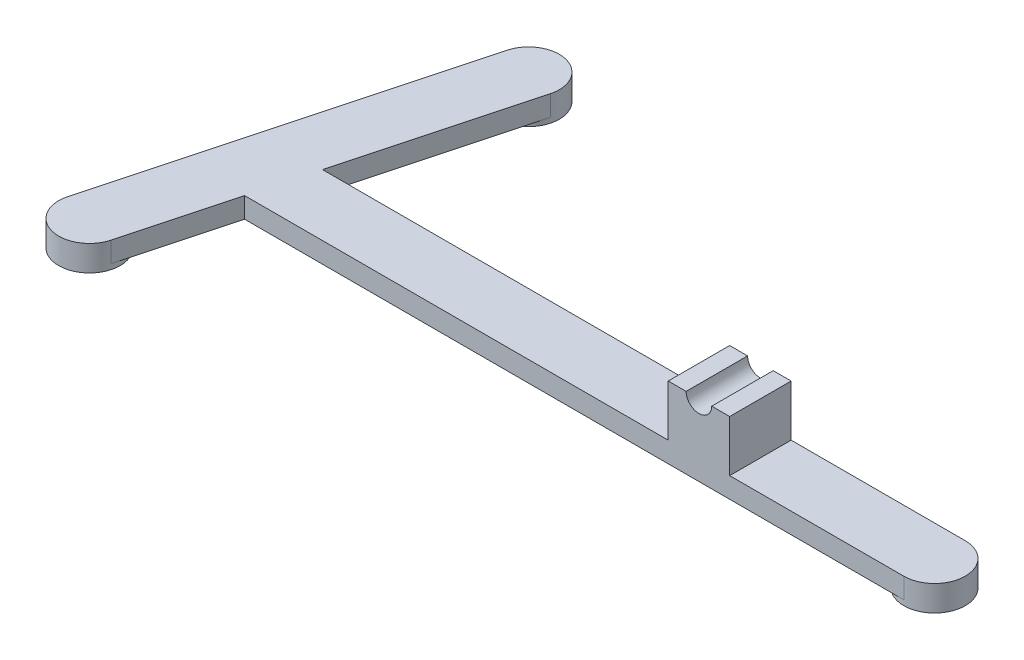
from build123d import *

# Parameters (mm, degrees)
BOSS_EXTRUDE3_DEPTH      = 4
BOSS_EXTRUDE3_2_DEPTH    = 4
BOSS_EXTRUDE4_DEPTH      = 4
BOSS_EXTRUDE4_DEPTH_BACK = 1
SKETCH2_5_R              = 6
SKETCH2_6_W              = 12
SKETCH2_6_H              = 12
BOSS_EXTRUDE5_DEPTH      = 14
SKETCH3_R                = 2.5
CUT_EXTRUDE1_DEPTH       = 14


with BuildPart() as part:
    # Sketch2 → Boss-Extrude3 (new body)
    with BuildSketch(Plane(origin=(0, 0, 0), x_dir=(1, 0, 0), z_dir=(0, 1, 0))):
        with BuildLine():
            ThreePointArc((-6.676022794, -14.008494556), (0.672446434, -9.765853869), (4.915087121, -17.114323097))
            Line((4.915087121, -17.114323097), (10.422223902, 3.438591174))
            Line((10.422223902, 3.438591174), (93.119532163, 3.438591174))
            Line((93.119532163, 3.438591174), (93.119532163, 15.438591174))
            Line((93.119532163, 15.438591174), (13.637614211, 15.438591174))
            Line((13.637614211, 15.438591174), (23.032420278, 50.500484743))
            ThreePointArc((23.032420278, 50.500484743), (15.68395105, 46.257844056), (11.441310363, 53.606313284))
            Line((11.441310363, 53.606313284), (-6.676022794, -14.008494556))
        make_face()
    extrude(amount=BOSS_EXTRUDE3_DEPTH)



with BuildPart() as body_2:
    # Sketch2 → Boss-Extrude3 2 (new body)
    with BuildSketch(Plane(origin=(0, 0, 0), x_dir=(1, 0, 0), z_dir=(0, 1, 0))):
        with BuildLine():
            Line((105.119532163, 15.438591174), (105.119532163, 3.438591174))
            Line((105.119532163, 3.438591174), (139.119532163, 3.438591174))
            ThreePointArc((139.119532163, 3.438591174), (133.119532163, 9.438591174), (139.119532163, 15.438591174))
            Line((139.119532163, 15.438591174), (105.119532163, 15.438591174))
        make_face()
    extrude(amount=BOSS_EXTRUDE3_2_DEPTH)


with BuildPart() as part_1:
    add(part.part)

    add(body_2.part)  # Boss-Extrude4 merges body 2
    # Sketch2_5 → Boss-Extrude4 (add, two sides: drawn at the far end of the back side and taken through both)
    with BuildSketch(Plane(origin=(0, 0, 0), x_dir=(1, 0, 0), z_dir=(0, 1, 0)).offset(-BOSS_EXTRUDE4_DEPTH_BACK)):
        with Locations((-0.880467837, -15.561408826)):
            Circle(SKETCH2_5_R)
        with Locations((17.236865321, 52.053399014)):
            Circle(SKETCH2_5_R)
        with Locations((139.119532163, 9.438591174)):
            Circle(SKETCH2_5_R)
    extrude(amount=BOSS_EXTRUDE4_DEPTH + BOSS_EXTRUDE4_DEPTH_BACK)

    # Sketch2_6 → Boss-Extrude5 (add)
    with BuildSketch(Plane(origin=(0, 0, 0), x_dir=(1, 0, 0), z_dir=(0, 1, 0))):
        with Locations((99.119532163, 9.438591174)):
            Rectangle(SKETCH2_6_W, SKETCH2_6_H)
    extrude(amount=BOSS_EXTRUDE5_DEPTH)

    # Sketch3 → Cut-Extrude1 (cut)
    with BuildSketch(Plane.XY.offset(-3.438591174)):
        with Locations((99.119532163, 14)):
            Circle(SKETCH3_R)
    extrude(amount=-CUT_EXTRUDE1_DEPTH, mode=Mode.SUBTRACT)


solid = part_1.part
